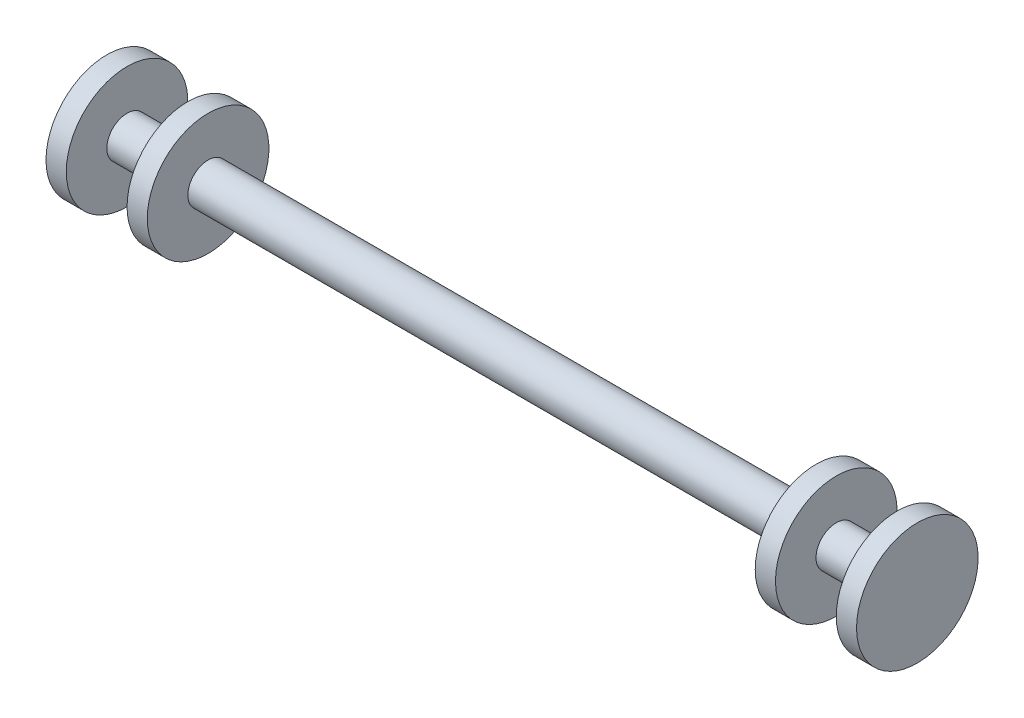
from build123d import *


with BuildPart() as part:
    # 草图1 → 旋转1 (revolve)
    with BuildSketch(Plane.XY):
        Polygon((30, 0), (-30, 0), (-30, 4), (-32, 4), (-32, 0), (-38, 0), (-38, 4), (-40, 4), (-40, 0), (-40, -2), (40, -2), (40, 0), (40, 4), (38, 4), (38, 0), (32, 0), (32, 4), (30, 4), align=None)
    revolve(axis=Axis((-40, -2, 0), (1, 0, 0)))


solid = part.part
